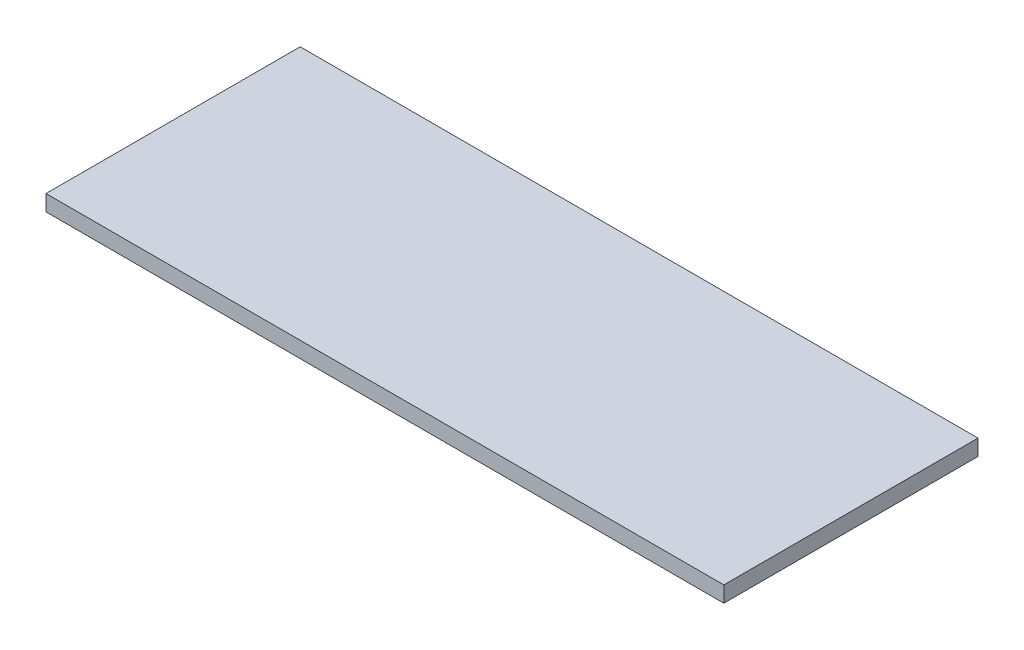
from build123d import *

# Parameters (mm, degrees)
SKETCH1_W           = 203.2
SKETCH1_H           = 76.2
BOSS_EXTRUDE1_DEPTH = 4.7625


with BuildPart() as part:
    # Sketch1 → Boss-Extrude1 (new body)
    with BuildSketch(Plane(origin=(0, 0, 0), x_dir=(1, 0, 0), z_dir=(0, 1, 0))):
        with Locations((101.6, -38.1)):
            Rectangle(SKETCH1_W, SKETCH1_H)
    extrude(amount=BOSS_EXTRUDE1_DEPTH)


solid = part.part
